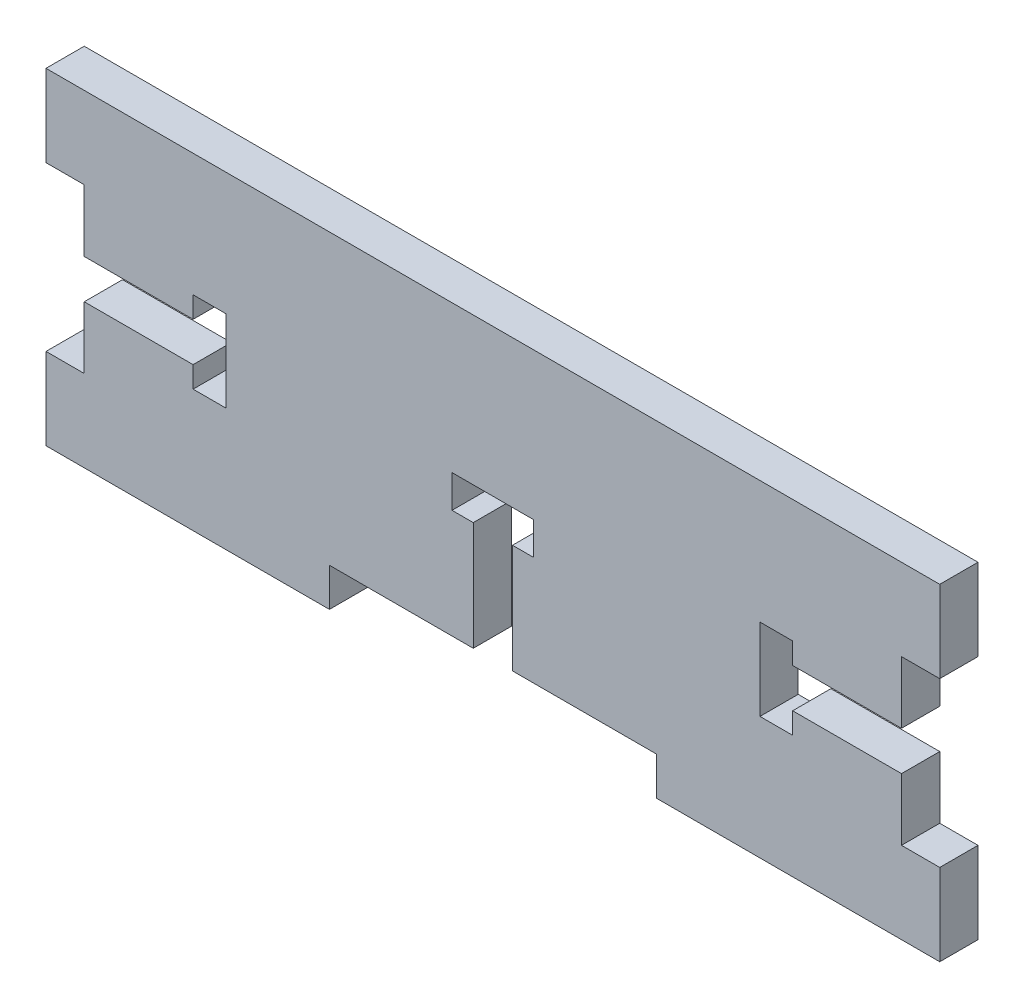
from build123d import *

# Parameters (mm, degrees)
SKETCH1_W           = 2.9718
SKETCH1_H           = 6.35
SKETCH1_H_2         = 3.3782
SKETCH1_H_3         = 2.9718
SKETCH1_W_2         = 19.05
BOSS_EXTRUDE1_DEPTH = 2.9718
CUT_EXTRUDE1_DEPTH  = 3.9718


with BuildPart() as part:
    # Sketch1 → Boss-Extrude1 (new body)
    with BuildSketch(Plane.XY):
        Polygon((-31.75, -6.35), (-31.75, -9.7282), (-12.7, -9.7282), (12.7, -9.7282), (31.75, -9.7282), (31.75, -6.35), (31.75, 6.35), (31.75, 12.7), (-31.75, 12.7), (-31.75, 6.35), align=None)
        with Locations((-33.2359, 9.525)):
            Rectangle(SKETCH1_W, SKETCH1_H)
        with Locations((-33.2359, -8.0391)):
            Rectangle(SKETCH1_W, SKETCH1_H_2)
        with Locations((-33.2359, -11.2141)):
            Rectangle(SKETCH1_W, SKETCH1_H_3)
        with Locations((-22.225, -11.2141)):
            Rectangle(SKETCH1_W_2, SKETCH1_H_3)
        with Locations((22.225, -11.2141)):
            Rectangle(SKETCH1_W_2, SKETCH1_H_3)
        with Locations((33.2359, -8.0391)):
            Rectangle(SKETCH1_W, SKETCH1_H_2)
        with Locations((33.2359, -11.2141)):
            Rectangle(SKETCH1_W, SKETCH1_H_3)
        with Locations((33.2359, 9.525)):
            Rectangle(SKETCH1_W, SKETCH1_H)
    extrude(amount=BOSS_EXTRUDE1_DEPTH)

    # Sketch2 → Cut-Extrude1 (cut, through all)
    with BuildSketch(Plane.XY.offset(2.9718)):
        Polygon((-20.7518, 3.175), (-20.7518, -3.175), (-23.2918, -3.175), (-23.2918, -1.524), (-31.75, -1.524), (-31.75, 1.524), (-23.2918, 1.524), (-23.2918, 3.175), align=None)
        Polygon((-3.175, 1.27), (3.175, 1.27), (3.175, -1.27), (1.524, -1.27), (1.524, -9.7282), (-1.524, -9.7282), (-1.524, -1.27), (-3.175, -1.27), align=None)
        Polygon((20.7518, 3.175), (20.7518, -3.175), (23.2918, -3.175), (23.2918, -1.524), (31.75, -1.524), (31.75, 1.524), (23.2918, 1.524), (23.2918, 3.175), align=None)
    extrude(amount=-CUT_EXTRUDE1_DEPTH, mode=Mode.SUBTRACT)


solid = part.part
